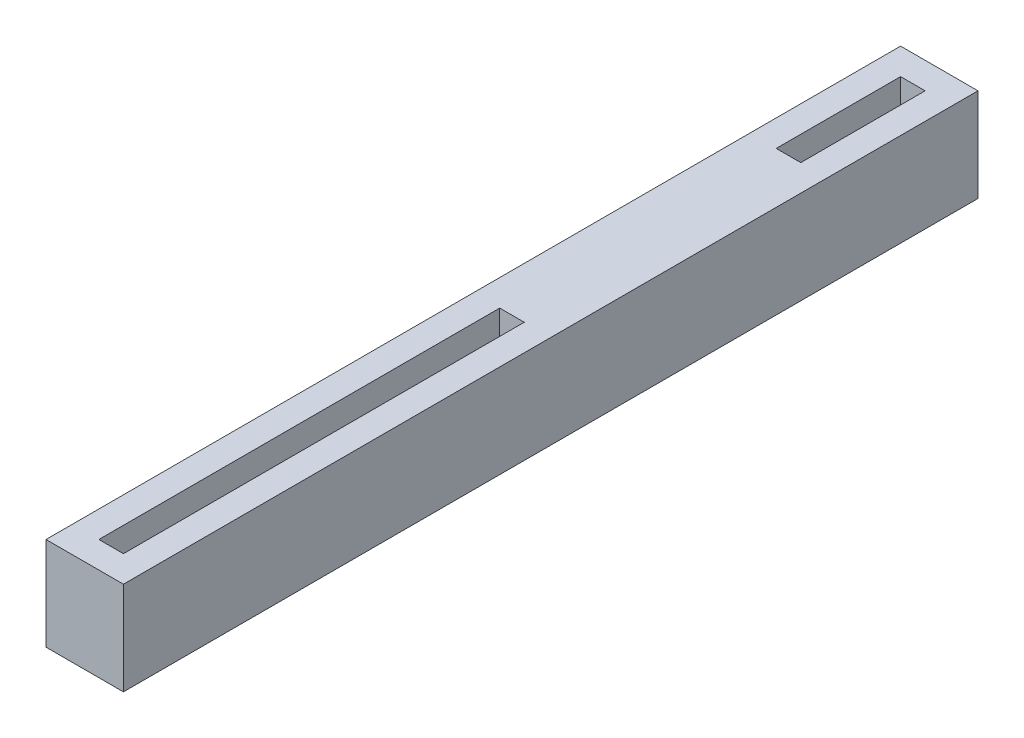
from build123d import *

# Parameters (mm, degrees)
SKETCH1_W           = 4.980670257
SKETCH1_H           = 54.9718421
BOSS_EXTRUDE1_DEPTH = 6
SKETCH2_W           = 1.580670257
SKETCH2_H           = 8
CUT_EXTRUDE2_DEPTH  = 7
SKETCH4_W           = 1.580670257
SKETCH4_H           = 25.78592105
CUT_EXTRUDE3_DEPTH  = 7


with BuildPart() as part:
    # Sketch1 → Boss-Extrude1 (new body)
    with BuildSketch(Plane(origin=(0, 0, 0), x_dir=(1, 0, 0), z_dir=(0, 1, 0))):
        with Locations((-11.806033203, 3.043742935)):
            Rectangle(SKETCH1_W, SKETCH1_H)
    extrude(amount=BOSS_EXTRUDE1_DEPTH)

    # Sketch2 → Cut-Extrude2 (cut)
    with BuildSketch(Plane(origin=(0, 6, 0), x_dir=(1, 0, 0), z_dir=(0, 1, 0))):
        with Locations((-11.806033203, 24.829663985)):
            Rectangle(SKETCH2_W, SKETCH2_H)
    extrude(amount=-CUT_EXTRUDE2_DEPTH, mode=Mode.SUBTRACT)

    # Sketch4 → Cut-Extrude3 (cut)
    with BuildSketch(Plane.XZ):
        with Locations((-11.806033203, 9.84921759)):
            Rectangle(SKETCH4_W, SKETCH4_H)
    extrude(amount=-CUT_EXTRUDE3_DEPTH, mode=Mode.SUBTRACT)


solid = part.part
